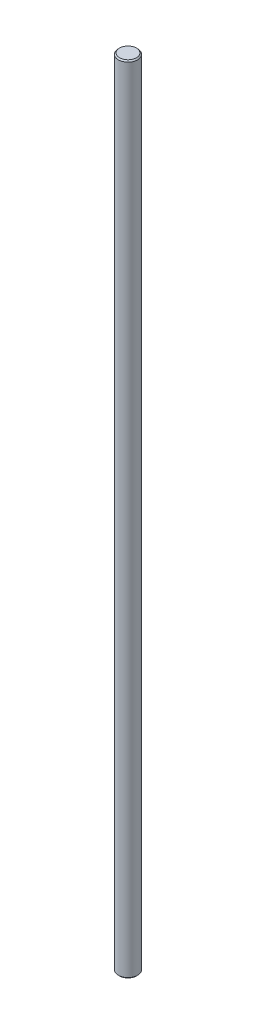
from build123d import *

# Parameters (mm, degrees)
SKETCH1_R           = 4
BOSS_EXTRUDE1_DEPTH = 165
CHAMFER1_SIZE       = 0.5


with BuildPart() as part:
    # Sketch1 → Boss-Extrude1 (new body, symmetric)
    with BuildSketch(Plane(origin=(0, 0, 0), x_dir=(1, 0, 0), z_dir=(0, 1, 0))):
        Circle(SKETCH1_R)
    extrude(amount=BOSS_EXTRUDE1_DEPTH, both=True)

    # Chamfer1
    chamfer1_edges = [part.edges().sort_by_distance(p)[0] for p in [
        (-4, -165, 0),
        (-4, 165, 0),
    ]]
    chamfer(chamfer1_edges, length=CHAMFER1_SIZE)


solid = part.part
